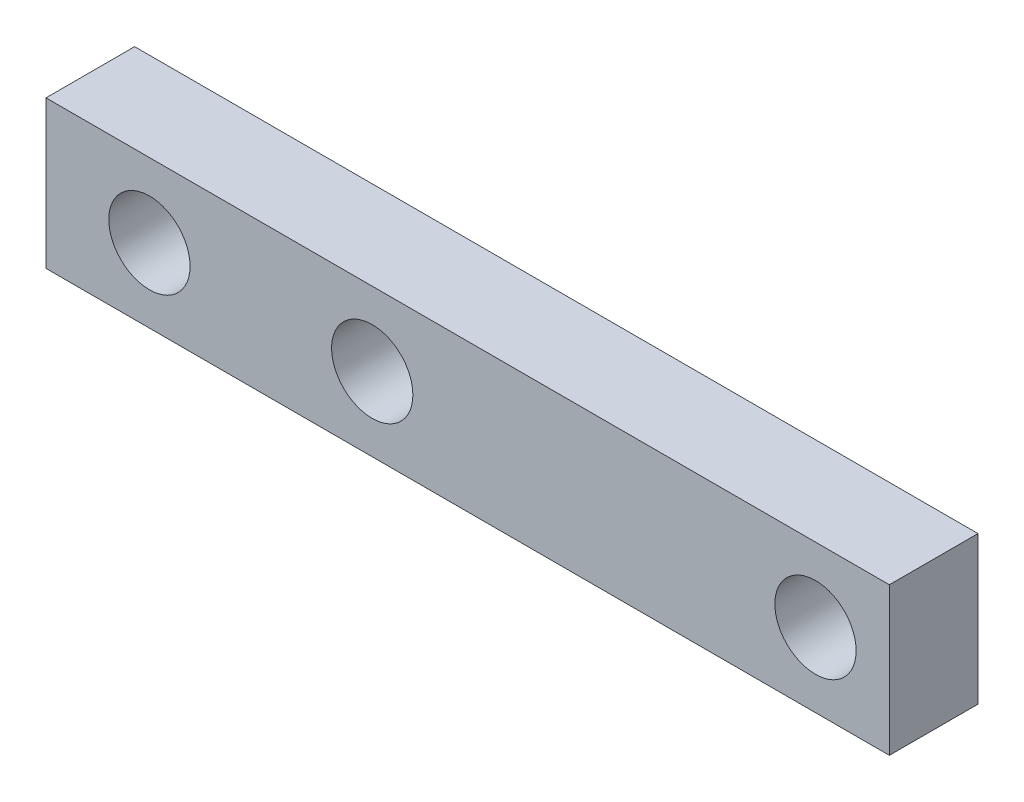
from build123d import *

# Parameters (mm, degrees)
SKETCH2_W           = 28.54
SKETCH2_H           = 5
SKETCH2_R           = 1.375
BOSS_EXTRUDE1_DEPTH = 3


with BuildPart() as part:
    # Sketch2 → Boss-Extrude1 (new body)
    with BuildSketch(Plane.XY):
        with Locations((14.27, 2.5)):
            Rectangle(SKETCH2_W, SKETCH2_H)
        with Locations((3.5, 2.5)):
            Circle(SKETCH2_R, mode=Mode.SUBTRACT)
        with Locations((11.04, 2.5)):
            Circle(SKETCH2_R, mode=Mode.SUBTRACT)
        with Locations((26.04, 2.5)):
            Circle(SKETCH2_R, mode=Mode.SUBTRACT)
    extrude(amount=BOSS_EXTRUDE1_DEPTH)


solid = part.part
